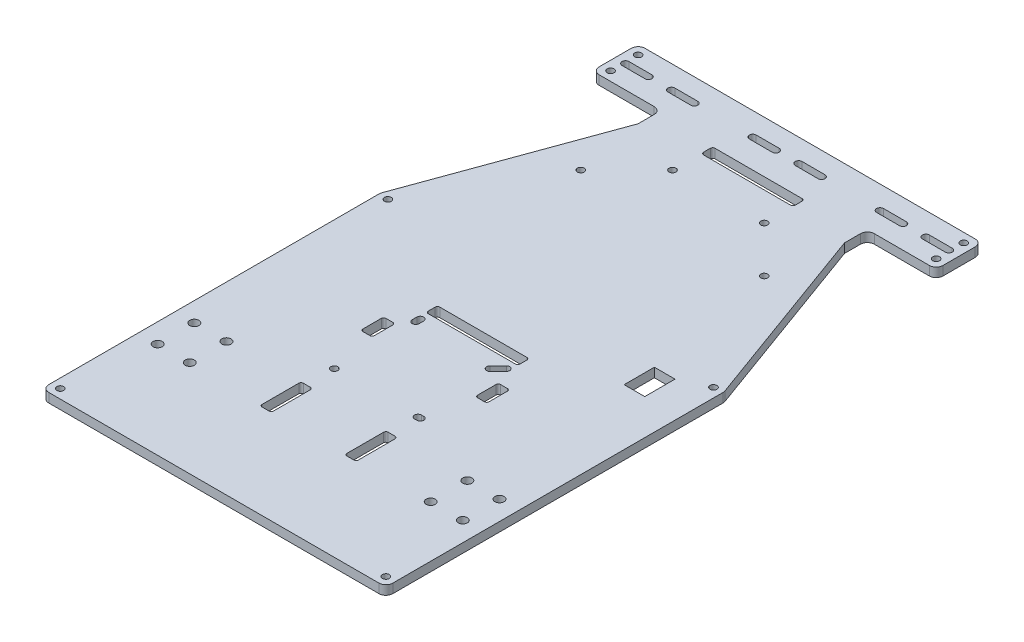
from build123d import *

# Parameters (mm, degrees)
SKETCH1_R           = 1.5
SKETCH1_R_2         = 2
SKETCH1_W           = 9
SKETCH1_H           = 13.2
BOSS_EXTRUDE1_DEPTH = 4
SKETCH2_R           = 1.5
CUT_EXTRUDE1_DEPTH  = 4


with BuildPart() as part:
    # Sketch1 → Boss-Extrude1 (new body)
    with BuildSketch(Plane(origin=(0, 0, 0), x_dir=(1, 0, 0), z_dir=(0, 1, 0))):
        with BuildLine():
            Line((-72, 110), (-48, 110))
            ThreePointArc((-48, 110), (-45.878679656, 109.121320344), (-45, 107))
            Line((-45, 107), (-45, 100))
            Line((-45, 100), (-74.819077862, 18.072756904))
            ThreePointArc((-74.819077862, 18.072756904), (-74.954423259, 17.567641007), (-75, 17.046696474))
            Line((-75, 17.046696474), (-75, -127))
            ThreePointArc((-75, -127), (-74.121320344, -129.121320344), (-72, -130))
            Line((-72, -130), (72, -130))
            ThreePointArc((72, -130), (74.121320344, -129.121320344), (75, -127))
            Line((75, -127), (75, 17.046696474))
            ThreePointArc((75, 17.046696474), (74.954423259, 17.567641007), (74.819077862, 18.072756904))
            Line((74.819077862, 18.072756904), (45, 100))
            Line((45, 100), (45, 107))
            ThreePointArc((45, 107), (45.878679656, 109.121320344), (48, 110))
            Line((48, 110), (72, 110))
            ThreePointArc((72, 110), (74.121320344, 110.878679656), (75, 113))
            Line((75, 113), (75, 127))
            ThreePointArc((75, 127), (74.121320344, 129.121320344), (72, 130))
            Line((72, 130), (-72, 130))
            ThreePointArc((-72, 130), (-74.121320344, 129.121320344), (-75, 127))
            Line((-75, 127), (-75, 113))
            ThreePointArc((-75, 113), (-74.121320344, 110.878679656), (-72, 110))
        make_face()
        with Locations((20, 90)):
            Circle(SKETCH1_R, mode=Mode.SUBTRACT)
        with Locations((-20, 90)):
            Circle(SKETCH1_R, mode=Mode.SUBTRACT)
        with Locations((-66.538461538, -72)):
            Circle(SKETCH1_R_2, mode=Mode.SUBTRACT)
        with Locations((-66.538461538, -88)):
            Circle(SKETCH1_R_2, mode=Mode.SUBTRACT)
        with Locations((-52.538461538, -72)):
            Circle(SKETCH1_R_2, mode=Mode.SUBTRACT)
        with Locations((-52.538461538, -88)):
            Circle(SKETCH1_R_2, mode=Mode.SUBTRACT)
        with Locations((52.538461538, -88)):
            Circle(SKETCH1_R_2, mode=Mode.SUBTRACT)
        with Locations((66.538461538, -88)):
            Circle(SKETCH1_R_2, mode=Mode.SUBTRACT)
        with Locations((66.538461538, -72)):
            Circle(SKETCH1_R_2, mode=Mode.SUBTRACT)
        with Locations((52.538461538, -72)):
            Circle(SKETCH1_R_2, mode=Mode.SUBTRACT)
        with Locations((-18.75, -58.75)):
            Circle(SKETCH1_R, mode=Mode.SUBTRACT)
        with BuildLine():
            Line((-70.5, 121.5), (-60.5, 121.5))
            ThreePointArc((-60.5, 121.5), (-59, 120), (-60.5, 118.5))
            Line((-60.5, 118.5), (-70.5, 118.5))
            ThreePointArc((-70.5, 118.5), (-72, 120), (-70.5, 121.5))
        make_face(mode=Mode.SUBTRACT)
        with BuildLine():
            Line((-19, -12.5), (19, -12.5))
            ThreePointArc((19, -12.5), (19.707106781, -12.792893219), (20, -13.5))
            Line((20, -13.5), (20, -16.5))
            ThreePointArc((20, -16.5), (19.707106781, -17.207106781), (19, -17.5))
            Line((19, -17.5), (-19, -17.5))
            ThreePointArc((-19, -17.5), (-19.707106781, -17.207106781), (-20, -16.5))
            Line((-20, -16.5), (-20, -13.5))
            ThreePointArc((-20, -13.5), (-19.707106781, -12.792893219), (-19, -12.5))
        make_face(mode=Mode.SUBTRACT)
        with BuildLine():
            Line((-15, 121.5), (-5, 121.5))
            ThreePointArc((-5, 121.5), (-3.5, 120), (-5, 118.5))
            Line((-5, 118.5), (-15, 118.5))
            ThreePointArc((-15, 118.5), (-16.5, 120), (-15, 121.5))
        make_face(mode=Mode.SUBTRACT)
        with Locations((55, 5)):
            Rectangle(SKETCH1_W, SKETCH1_H, mode=Mode.SUBTRACT)
        with BuildLine():
            Line((-50.5, 121.5), (-40.5, 121.5))
            ThreePointArc((-40.5, 121.5), (-39, 120), (-40.5, 118.5))
            Line((-40.5, 118.5), (-50.5, 118.5))
            ThreePointArc((-50.5, 118.5), (-52, 120), (-50.5, 121.5))
        make_face(mode=Mode.SUBTRACT)
        with BuildLine():
            Line((5, 118.5), (15, 118.5))
            ThreePointArc((15, 118.5), (16.5, 120), (15, 121.5))
            Line((15, 121.5), (5, 121.5))
            ThreePointArc((5, 121.5), (3.5, 120), (5, 118.5))
        make_face(mode=Mode.SUBTRACT)
        with BuildLine():
            Line((19, 102.5), (-19, 102.5))
            ThreePointArc((-19, 102.5), (-19.707106781, 102.792893219), (-20, 103.5))
            Line((-20, 103.5), (-20, 106.5))
            ThreePointArc((-20, 106.5), (-19.707106781, 107.207106781), (-19, 107.5))
            Line((-19, 107.5), (19, 107.5))
            ThreePointArc((19, 107.5), (19.707106781, 107.207106781), (20, 106.5))
            Line((20, 106.5), (20, 103.5))
            ThreePointArc((20, 103.5), (19.707106781, 102.792893219), (19, 102.5))
        make_face(mode=Mode.SUBTRACT)
        with BuildLine():
            Line((-17.25, -21.25), (-17.25, -23.25))
            ThreePointArc((-17.25, -23.25), (-18.75, -24.75), (-20.25, -23.25))
            Line((-20.25, -23.25), (-20.25, -21.25))
            ThreePointArc((-20.25, -21.25), (-18.75, -19.75), (-17.25, -21.25))
        make_face(mode=Mode.SUBTRACT)
        with BuildLine():
            Line((18.75, -60.25), (17.75, -60.25))
            ThreePointArc((17.75, -60.25), (16.25, -58.75), (17.75, -57.25))
            Line((17.75, -57.25), (18.75, -57.25))
            ThreePointArc((18.75, -57.25), (20.25, -58.75), (18.75, -60.25))
        make_face(mode=Mode.SUBTRACT)
        with BuildLine():
            Line((19.810660172, -22.310660172), (16.275126266, -25.846194078))
            ThreePointArc((16.275126266, -25.846194078), (14.153805922, -25.846194078), (14.153805922, -23.724873734))
            Line((14.153805922, -23.724873734), (17.689339828, -20.189339828))
            ThreePointArc((17.689339828, -20.189339828), (19.810660172, -20.189339828), (19.810660172, -22.310660172))
        make_face(mode=Mode.SUBTRACT)
        with BuildLine():
            Line((50.5, 121.5), (40.5, 121.5))
            ThreePointArc((40.5, 121.5), (39, 120), (40.5, 118.5))
            Line((40.5, 118.5), (50.5, 118.5))
            ThreePointArc((50.5, 118.5), (52, 120), (50.5, 121.5))
        make_face(mode=Mode.SUBTRACT)
        with BuildLine():
            Line((60.5, 118.5), (70.5, 118.5))
            ThreePointArc((70.5, 118.5), (72, 120), (70.5, 121.5))
            Line((70.5, 121.5), (60.5, 121.5))
            ThreePointArc((60.5, 121.5), (59, 120), (60.5, 118.5))
        make_face(mode=Mode.SUBTRACT)
    extrude(amount=BOSS_EXTRUDE1_DEPTH)

    # Sketch2 → Cut-Extrude1 (cut)
    with BuildSketch(Plane(origin=(0, 4, 0), x_dir=(1, 0, 0), z_dir=(0, 1, 0))):
        with Locations((-71, -126)):
            Circle(SKETCH2_R)
        with Locations((-71, 16.870369494)):
            Circle(SKETCH2_R)
        with Locations((-71, 114)):
            Circle(SKETCH2_R)
        with Locations((-71, 126)):
            Circle(SKETCH2_R)
        with Locations((71, 16.870369494)):
            Circle(SKETCH2_R)
        with Locations((71, -126)):
            Circle(SKETCH2_R)
        with Locations((71, 114)):
            Circle(SKETCH2_R)
        with Locations((71, 126)):
            Circle(SKETCH2_R)
        with Locations((-40, 70)):
            Circle(SKETCH2_R)
        with Locations((40, 70)):
            Circle(SKETCH2_R)
        with BuildLine():
            Line((-20, -71), (-17, -71))
            ThreePointArc((-17, -71), (-16.292893219, -71.292893219), (-16, -72))
            Line((-16, -72), (-16, -88))
            ThreePointArc((-16, -88), (-16.292893219, -88.707106781), (-17, -89))
            Line((-17, -89), (-20, -89))
            ThreePointArc((-20, -89), (-20.707106781, -88.707106781), (-21, -88))
            Line((-21, -88), (-21, -72))
            ThreePointArc((-21, -72), (-20.707106781, -71.292893219), (-20, -71))
        make_face()
        with BuildLine():
            Line((-26.5, -28.5), (-23.5, -28.5))
            ThreePointArc((-23.5, -28.5), (-22.792893219, -28.792893219), (-22.5, -29.5))
            Line((-22.5, -29.5), (-22.5, -37.5))
            ThreePointArc((-22.5, -37.5), (-22.792893219, -38.207106781), (-23.5, -38.5))
            Line((-23.5, -38.5), (-26.5, -38.5))
            ThreePointArc((-26.5, -38.5), (-27.207106781, -38.207106781), (-27.5, -37.5))
            Line((-27.5, -37.5), (-27.5, -29.5))
            ThreePointArc((-27.5, -29.5), (-27.207106781, -28.792893219), (-26.5, -28.5))
        make_face()
        with BuildLine():
            Line((26.5, -38.5), (23.5, -38.5))
            ThreePointArc((23.5, -38.5), (22.792893219, -38.207106781), (22.5, -37.5))
            Line((22.5, -37.5), (22.5, -29.5))
            ThreePointArc((22.5, -29.5), (22.792893219, -28.792893219), (23.5, -28.5))
            Line((23.5, -28.5), (26.5, -28.5))
            ThreePointArc((26.5, -28.5), (27.207106781, -28.792893219), (27.5, -29.5))
            Line((27.5, -29.5), (27.5, -37.5))
            ThreePointArc((27.5, -37.5), (27.207106781, -38.207106781), (26.5, -38.5))
        make_face()
        with BuildLine():
            Line((16, -72), (16, -88))
            ThreePointArc((16, -88), (16.292893219, -88.707106781), (17, -89))
            Line((17, -89), (20, -89))
            ThreePointArc((20, -89), (20.707106781, -88.707106781), (21, -88))
            Line((21, -88), (21, -72))
            ThreePointArc((21, -72), (20.707106781, -71.292893219), (20, -71))
            Line((20, -71), (17, -71))
            ThreePointArc((17, -71), (16.292893219, -71.292893219), (16, -72))
        make_face()
    extrude(amount=-CUT_EXTRUDE1_DEPTH, mode=Mode.SUBTRACT)


solid = part.part
